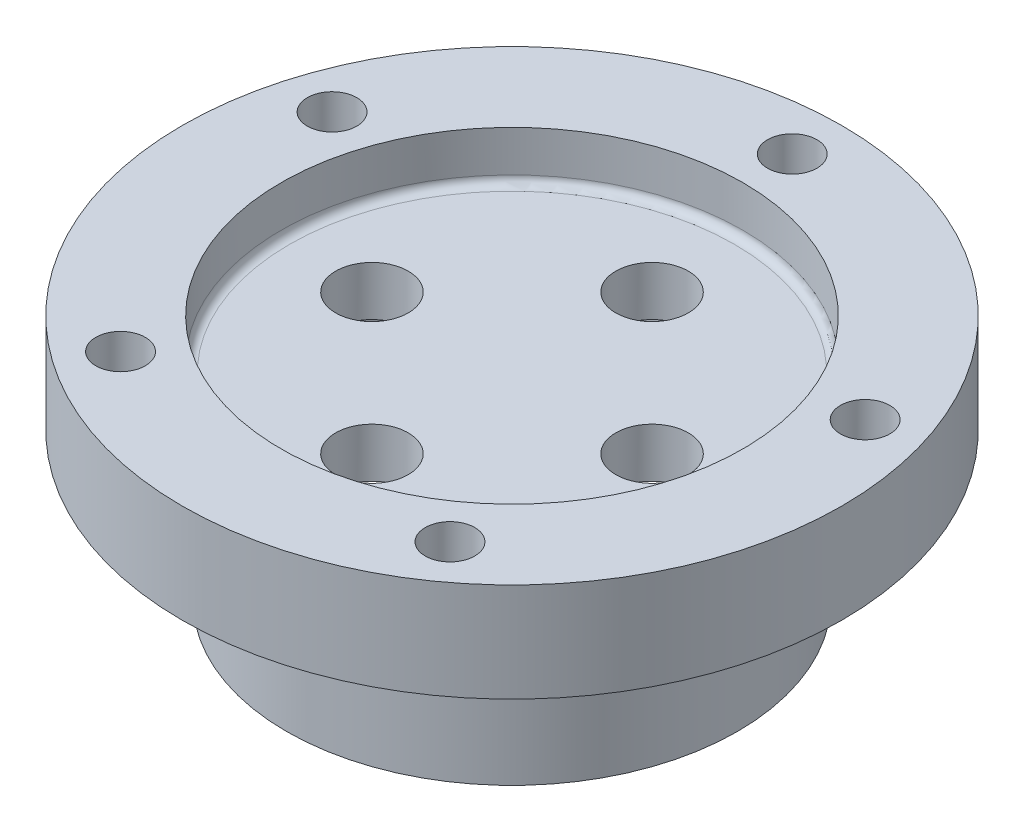
from build123d import *

# Parameters (mm, degrees)
SKETCH2_R          = 3.4925
CUT_EXTRUDE1_DEPTH = 49.775275499
SKETCH3_R          = 2.38125
CUT_EXTRUDE2_DEPTH = 51.824798635
CIRPATTERN1_COUNT  = 5
FILLET1_R          = 0.79375


with BuildPart() as part:
    # Sketch1 → Revolve1 (revolve)
    with BuildSketch(Plane.XY):
        Polygon((18.542, -14.2875), (18.542, 0), (0, 0), (0, 4.7625), (22.225, 4.7625), (22.225, 9.525), (31.75, 9.525), (31.75, 0), (21.717, 0), (21.717, -14.2875), align=None)
    revolve(axis=Axis((0, 0, 0), (0, 1, 0)))

    # Sketch2 → Cut-Extrude1 (cut, through all)
    with BuildSketch(Plane(origin=(0, 4.7625, 0), x_dir=(1, 0, 0), z_dir=(0, 1, 0))):
        with Locations((-13.4874, 0)):
            Circle(SKETCH2_R)
        with Locations((0, 13.4874)):
            Circle(SKETCH2_R)
        with Locations((13.4874, 0)):
            Circle(SKETCH2_R)
        with Locations((0, -13.4874)):
            Circle(SKETCH2_R)
    extrude(amount=-CUT_EXTRUDE1_DEPTH, mode=Mode.SUBTRACT)

    # Sketch3 → Cut-Extrude2 (cut, through all)
    with BuildSketch(Plane(origin=(0, 9.525, 0), x_dir=(1, 0, 0), z_dir=(0, 1, 0))):
        with Locations((0, 26.9875)):
            Circle(SKETCH3_R)
    cut_extrude2 = extrude(amount=-CUT_EXTRUDE2_DEPTH, mode=Mode.SUBTRACT)

    # CirPattern1: Cut-Extrude2 ×5 about axis
    cirpattern1_axis = Axis((0, 14.76375, 0), (0, -1, 0))
    for i in range(1, CIRPATTERN1_COUNT):
        add(cut_extrude2.rotate(cirpattern1_axis, i * 360 / CIRPATTERN1_COUNT), mode=Mode.SUBTRACT)

    # Fillet1
    fillet1_edges = [part.edges().sort_by_distance(p)[0] for p in [
        (-22.225, 4.7625, 0),
        (-18.542, 0, 0),
    ]]
    fillet(fillet1_edges, radius=FILLET1_R)


solid = part.part
